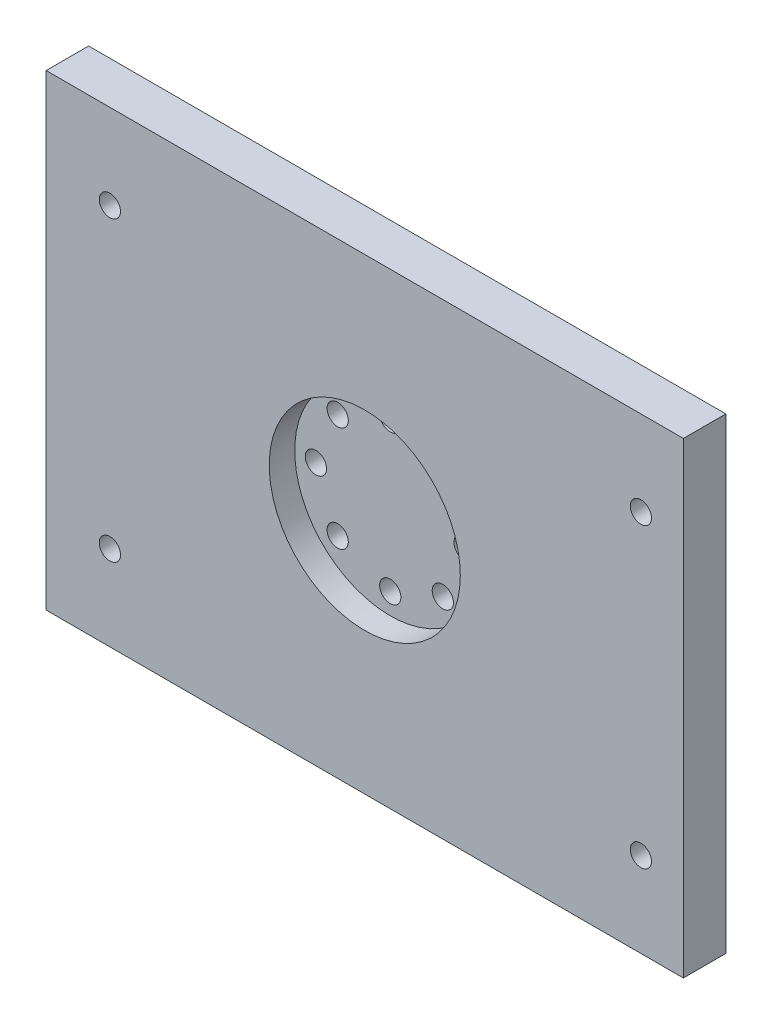
from build123d import *

# Parameters (mm, degrees)
SKETCH1_W             = 150
SKETCH1_H             = 110
BOSS_EXTRUDE2_DEPTH   = 10
SKETCH2_R             = 22.49
CUT_EXTRUDE1_DEPTH    = 6
F_5_0MM_DOWEL_HOLE1_D = 5
F_5_0MM_DOWEL_HOLE2_D = 5


with BuildPart() as part:
    # Sketch1 → Boss-Extrude2 (new body)
    with BuildSketch(Plane.XY):
        with Locations((-50.323383085, -0.820895522)):
            Rectangle(SKETCH1_W, SKETCH1_H)
    extrude(amount=BOSS_EXTRUDE2_DEPTH)

    # Sketch2 → Cut-Extrude1 (cut)
    with BuildSketch(Plane.XY.offset(10)):
        with Locations((-50.323383085, 0)):
            Circle(SKETCH2_R)
    extrude(amount=-CUT_EXTRUDE1_DEPTH, mode=Mode.SUBTRACT)

    # Ø5.0mm Dowel Hole1 (through all)
    with Locations(Plane(origin=(-50.323383085, 17.5, 4), x_dir=(1, 0, 0), z_dir=(0, 0, 1))):
        with Locations((0, 0), (-12.37436867, -5.125631329), (-17.5, -17.5), (-12.37436867, -29.874368671), (0, -35), (12.374368671, -29.874368671), (17.5, -17.5), (12.374368671, -5.125631329)):
            Hole(F_5_0MM_DOWEL_HOLE1_D / 2)

    # Ø5.0mm Dowel Hole2 (through all)
    with Locations(Plane(origin=(-110.323383085, 34.179104478, 10), x_dir=(1, 0, 0), z_dir=(0, 0, 1))):
        with Locations((0, 0), (125, 0), (125, -70), (0, -70)):
            Hole(F_5_0MM_DOWEL_HOLE2_D / 2)


solid = part.part
